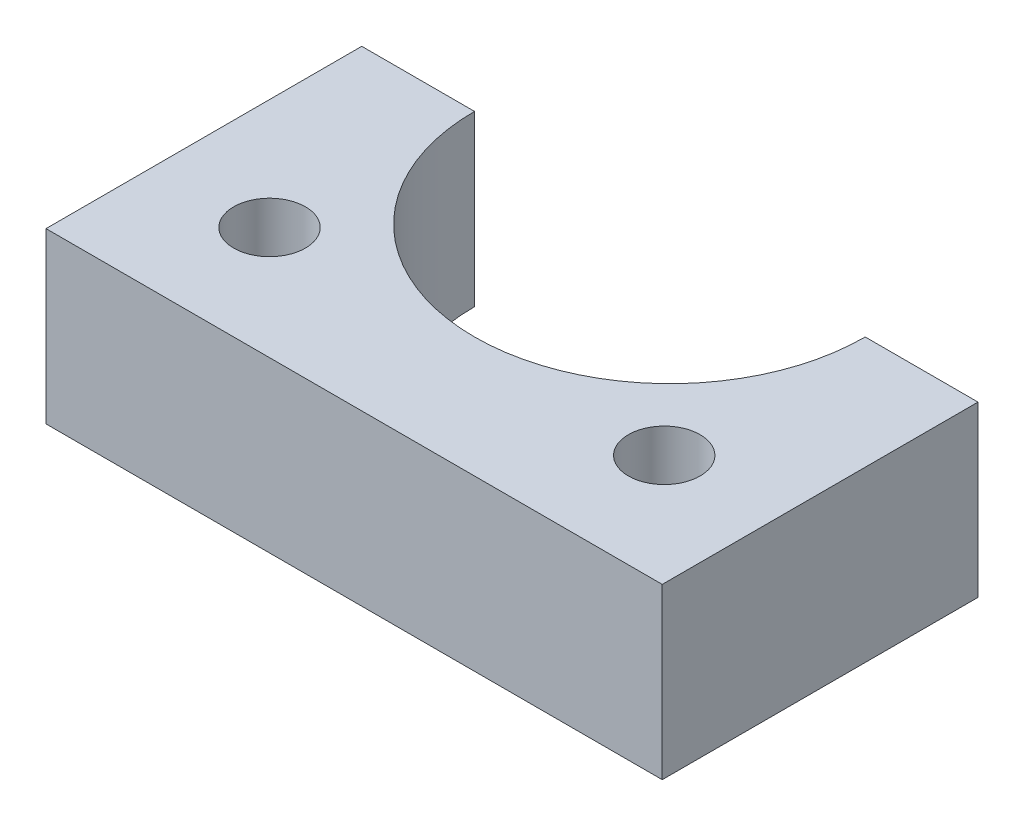
from build123d import *

# Parameters (mm, degrees)
BOSS_EXTRUDE1_DEPTH = 9.525
SKETCH3_R           = 2.0193
CUT_EXTRUDE2_DEPTH  = 10.525


with BuildPart() as part:
    # Sketch1 → Boss-Extrude1 (new body)
    with BuildSketch(Plane(origin=(0, 0, 0), x_dir=(1, 0, 0), z_dir=(0, 1, 0))):
        with BuildLine():
            Line((-10.999999971, -17.78), (10.999999971, -17.78))
            Line((10.999999971, -17.78), (17.349999971, -17.78))
            Line((17.349999971, -17.78), (17.349999971, 0))
            Line((17.349999971, 0), (10.999999971, 0))
            ThreePointArc((10.999999971, 0), (0, -10.999999971), (-10.999999971, 0))
            Line((-10.999999971, 0), (-17.349999971, 0))
            Line((-17.349999971, 0), (-17.349999971, -17.78))
            Line((-17.349999971, -17.78), (-10.999999971, -17.78))
        make_face()
    extrude(amount=BOSS_EXTRUDE1_DEPTH)

    # Sketch3 → Cut-Extrude2 (cut, through all)
    with BuildSketch(Plane(origin=(0, 9.525, 0), x_dir=(1, 0, 0), z_dir=(0, 1, 0))):
        with Locations((11.1125, -11.43)):
            Circle(SKETCH3_R)
        with Locations((-11.1125, -11.43)):
            Circle(SKETCH3_R)
    extrude(amount=-CUT_EXTRUDE2_DEPTH, mode=Mode.SUBTRACT)


solid = part.part
